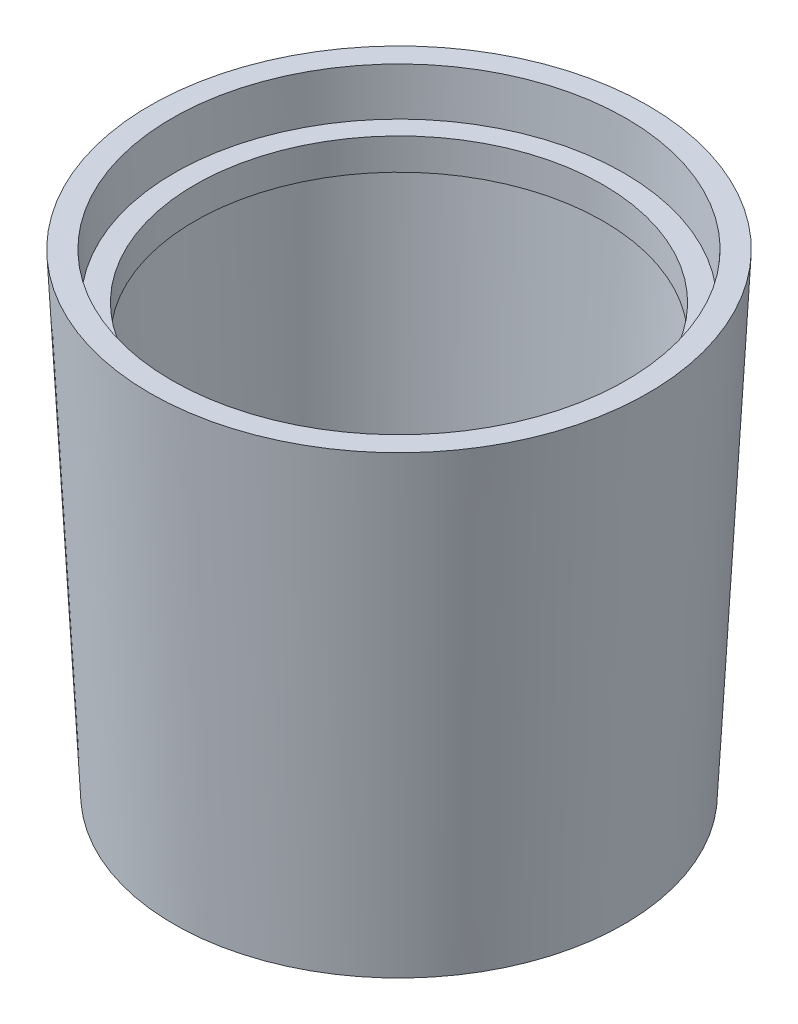
from build123d import *


with BuildPart() as part:
    # 草图1 → 旋转1 (revolve)
    with BuildSketch(Plane.XY):
        Polygon((-383.448105995, 0), (-295.031990142, 0), (-246.334801678, 957.956271748), (-291.060517996, 957.956271748), (-295.815730173, 864.413184913), (-337.722580965, 864.413184913), (-337.722580965, 800.688106683), (-299.893291713, 800.688106683), (-338.130509359, 48.497197642), (-383.448105995, 48.497197642), align=None)
    revolve(axis=Axis((-752, 0, 0), (0, 1, 0)))


solid = part.part
